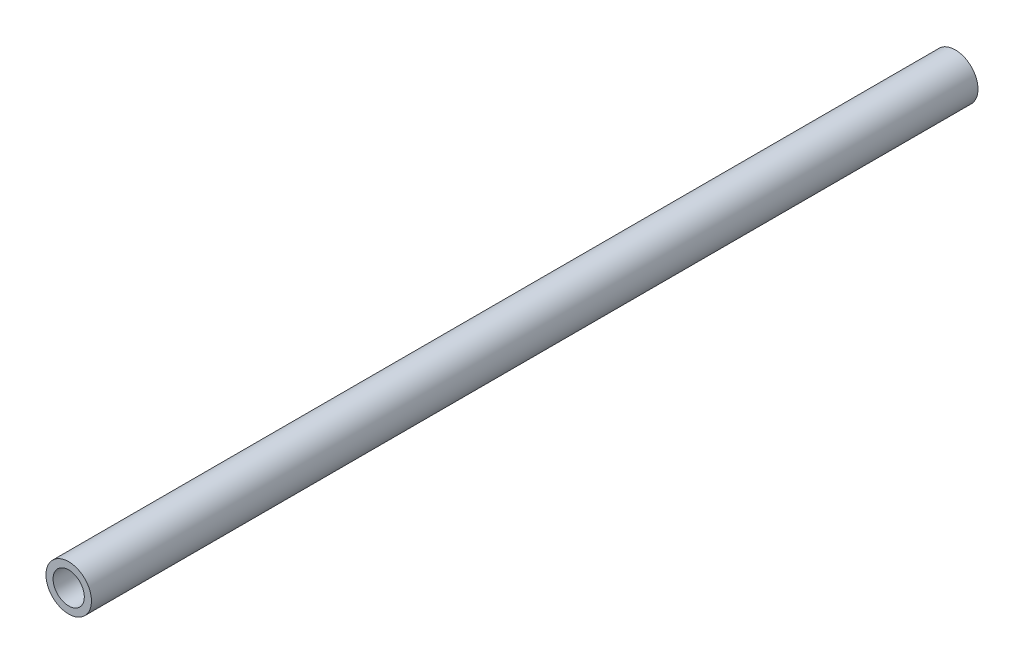
from build123d import *

# Parameters (mm, degrees)
SKETCH1_R           = 12.7
SKETCH1_R_2         = 8.73125
BOSS_EXTRUDE1_DEPTH = 495.3


with BuildPart() as part:
    # Sketch1 → Boss-Extrude1 (new body)
    with BuildSketch(Plane.XY):
        Circle(SKETCH1_R)
        Circle(SKETCH1_R_2, mode=Mode.SUBTRACT)
    extrude(amount=BOSS_EXTRUDE1_DEPTH)


solid = part.part
